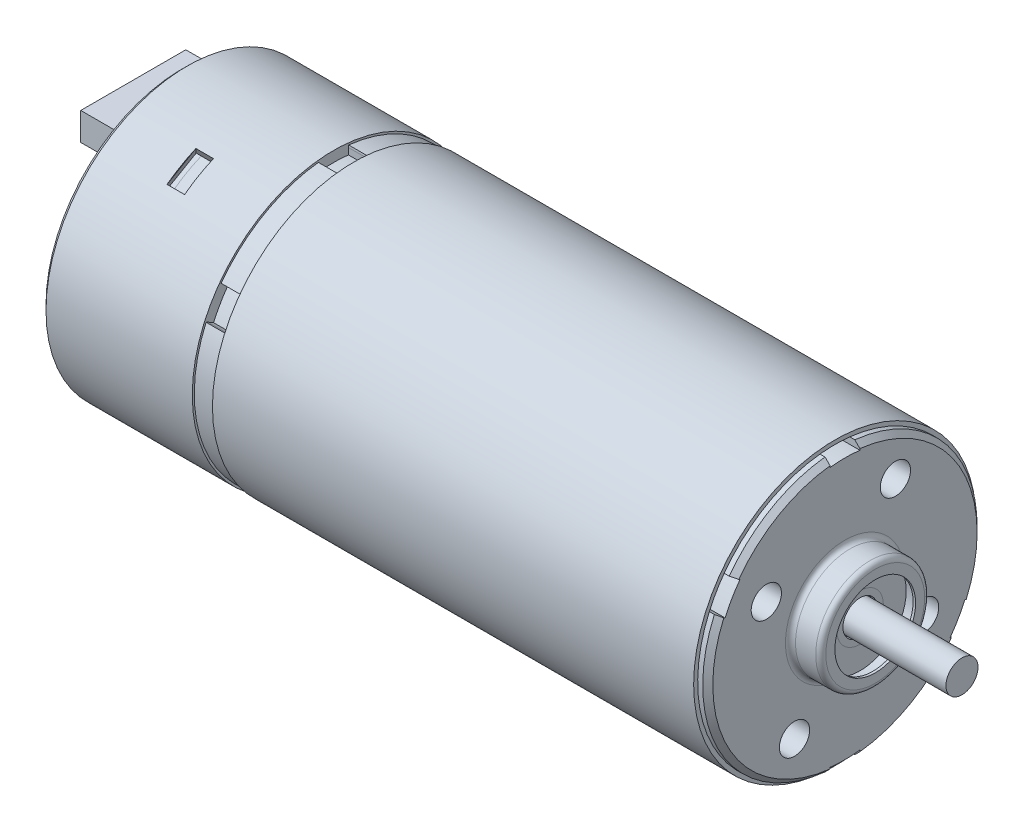
from build123d import *

# Parameters (mm, degrees)
SKETCH1_R               = 13.6
BOSS_EXTRUDE1_DEPTH     = 50.7
CUT_EXTRUDE1_DEPTH      = 55.225547485
SKETCH3_R               = 14
SKETCH3_R_2             = 13.6
BOSS_EXTRUDE2_DEPTH     = 47.7
SKETCH4_R               = 14
BOSS_EXTRUDE3_DEPTH     = 15
BOSS_EXTRUDE4_DEPTH     = 2
SKETCH6_R               = 1.5
CUT_EXTRUDE2_DEPTH      = 7
SKETCH7_R               = 5.4
BOSS_EXTRUDE5_DEPTH     = 3
SKETCH8_R               = 4
CUT_EXTRUDE3_DEPTH      = 1.5
SKETCH9_R               = 1.7
CUT_EXTRUDE4_DEPTH      = 0.5
SKETCH11_R              = 1.5875
BOSS_EXTRUDE6_DEPTH     = 10.6
SKETCH12_R              = 4.570841128
SKETCH12_R_2            = 4
CUT_EXTRUDE5_DEPTH      = 1.25
FILLET1_R               = 0.5
CHAMFER1_SIZE           = 0.5
CUT_EXTRUDE6_REACH      = 75.756
CUT_EXTRUDE6_END_RADIUS = 12.956768024
SKETCH13_W              = 1.739955734
SKETCH13_H              = 3.306373614
CUT_EXTRUDE7_DEPTH      = 0.5
CUT_EXTRUDE8_DEPTH      = 3.306373613
BOSS_EXTRUDE7_DEPTH     = 3.306373613
SKETCH17_W              = 10.414574722
SKETCH17_H              = 2.75
BOSS_EXTRUDE8_DEPTH     = 4.85
SKETCH18_W              = 9.614574722
SKETCH18_H              = 1.95
CUT_EXTRUDE10_DEPTH     = 4.85
SKETCH20_R              = 0.7
BOSS_EXTRUDE9_DEPTH     = 4.85


with BuildPart() as part:
    # Sketch1 → Boss-Extrude1 (new body)
    with BuildSketch(Plane(origin=(0, 0, 0), x_dir=(0, 0, -1), z_dir=(1, 0, 0))):
        Circle(SKETCH1_R)
    extrude(amount=-BOSS_EXTRUDE1_DEPTH)

    # Sketch2 → Cut-Extrude1 (cut, through all)
    with BuildSketch(Plane(origin=(0, 0, 0), x_dir=(0, 0, -1), z_dir=(1, 0, 0))):
        with BuildLine():
            Line((-1.476652596, 12.872347678), (-1.476652596, 14.372812182))
            Line((-1.476652596, 14.372812182), (1.476652596, 14.372812182))
            Line((1.476652596, 14.372812182), (1.476652596, 12.872347678))
            ThreePointArc((1.476652596, 12.872347678), (0, 12.956768024), (-1.476652596, 12.872347678))
        make_face()
        with BuildLine():
            Line((1.476652596, -12.872347678), (1.476652596, -14.372812182))
            Line((1.476652596, -14.372812182), (-1.476652596, -14.372812182))
            Line((-1.476652596, -14.372812182), (-1.476652596, -12.872347678))
            ThreePointArc((-1.476652596, -12.872347678), (0, -12.956768024), (1.476652596, -12.872347678))
        make_face()
        with BuildLine():
            Line((11.886106393, -5.157355179), (13.185546772, -5.907587431))
            Line((13.185546772, -5.907587431), (11.708894176, -8.465224751))
            Line((11.708894176, -8.465224751), (10.409453797, -7.714992499))
            ThreePointArc((10.409453797, -7.714992499), (11.220890259, -6.478384012), (11.886106393, -5.157355179))
        make_face()
        with BuildLine():
            Line((-11.886106393, 5.157355179), (-13.185546772, 5.907587431))
            Line((-13.185546772, 5.907587431), (-11.708894176, 8.465224751))
            Line((-11.708894176, 8.465224751), (-10.409453797, 7.714992499))
            ThreePointArc((-10.409453797, 7.714992499), (-11.220890259, 6.478384012), (-11.886106393, 5.157355179))
        make_face()
    extrude(amount=-CUT_EXTRUDE1_DEPTH, mode=Mode.SUBTRACT)



with BuildPart() as body_2:
    # Sketch3 → Boss-Extrude2 (new body)
    with BuildSketch(Plane(origin=(-1, 0, 0), x_dir=(0, 0, -1), z_dir=(1, 0, 0))):
        Circle(SKETCH3_R)
        Circle(SKETCH3_R_2, mode=Mode.SUBTRACT)
    extrude(amount=-BOSS_EXTRUDE2_DEPTH)


with BuildPart() as body_3:
    # Sketch4 → Boss-Extrude3 (new body)
    with BuildSketch(Plane.ZY.offset(50.7)):
        Circle(SKETCH4_R)
    extrude(amount=BOSS_EXTRUDE3_DEPTH)


with BuildPart() as part_1:
    add(part.part)

    add(body_2.part)  # Boss-Extrude4 merges body 2

    add(body_3.part)  # Boss-Extrude4 merges body 3
    # Sketch5 → Boss-Extrude4 (add)
    with BuildSketch(Plane(origin=(-50.7, 0, 0), x_dir=(0, 0, -1), z_dir=(1, 0, 0))):
        with BuildLine():
            Line((1.476652596, 13.519596781), (1.498368075, 13.71841438))
            ThreePointArc((1.498368075, 13.71841438), (11.951150572, 6.9), (12.629679391, -5.561582373))
            Line((12.629679391, -5.561582373), (12.446640559, -5.48097973))
            ThreePointArc((12.446640559, -5.48097973), (11.777945491, 6.8), (1.476652596, 13.519596781))
        make_face()
        with BuildLine():
            Line((-1.476652596, 13.519596781), (-1.498368075, 13.71841438))
            ThreePointArc((-1.498368075, 13.71841438), (-6.9, 11.951150572), (-11.131311316, 8.156832007))
            Line((-11.131311316, 8.156832007), (-10.969987963, 8.038617051))
            ThreePointArc((-10.969987963, 8.038617051), (-6.8, 11.777945491), (-1.476652596, 13.519596781))
        make_face()
        with BuildLine():
            Line((10.969987963, -8.038617051), (11.131311316, -8.156832007))
            ThreePointArc((11.131311316, -8.156832007), (6.9, -11.951150572), (1.498368075, -13.71841438))
            Line((1.498368075, -13.71841438), (1.476652596, -13.519596781))
            ThreePointArc((1.476652596, -13.519596781), (6.8, -11.777945491), (10.969987963, -8.038617051))
        make_face()
        with BuildLine():
            Line((-1.476652596, -13.519596781), (-1.498368075, -13.71841438))
            ThreePointArc((-1.498368075, -13.71841438), (-11.951150572, -6.9), (-12.629679391, 5.561582373))
            Line((-12.629679391, 5.561582373), (-12.446640559, 5.48097973))
            ThreePointArc((-12.446640559, 5.48097973), (-11.777945491, -6.8), (-1.476652596, -13.519596781))
        make_face()
    extrude(amount=BOSS_EXTRUDE4_DEPTH)

    # Sketch6 → Cut-Extrude2 (cut)
    with BuildSketch(Plane(origin=(0, 0, 0), x_dir=(0, 0, -1), z_dir=(1, 0, 0))):
        with Locations((-5, -8.660254038)):
            Circle(SKETCH6_R)
        with Locations((5, 8.660254038)):
            Circle(SKETCH6_R)
        with Locations((-7.794228634, 4.5)):
            Circle(SKETCH6_R)
        with Locations((7.794228634, -4.5)):
            Circle(SKETCH6_R)
    extrude(amount=-CUT_EXTRUDE2_DEPTH, mode=Mode.SUBTRACT)

    # Sketch7 → Boss-Extrude5 (add)
    with BuildSketch(Plane(origin=(0, 0, 0), x_dir=(0, 0, -1), z_dir=(1, 0, 0))):
        Circle(SKETCH7_R)
    extrude(amount=BOSS_EXTRUDE5_DEPTH)

    # Sketch8 → Cut-Extrude3 (cut)
    with BuildSketch(Plane(origin=(3, 0, 0), x_dir=(0, 0, -1), z_dir=(1, 0, 0))):
        Circle(SKETCH8_R)
    extrude(amount=-CUT_EXTRUDE3_DEPTH, mode=Mode.SUBTRACT)

    # Sketch9 → Cut-Extrude4 (cut)
    with BuildSketch(Plane(origin=(1.5, 0, 0), x_dir=(0, 0, -1), z_dir=(1, 0, 0))):
        Circle(SKETCH9_R)
    extrude(amount=-CUT_EXTRUDE4_DEPTH, mode=Mode.SUBTRACT)

    # Sketch12 → Cut-Extrude5 (cut)
    with BuildSketch(Plane(origin=(1.5, 0, 0), x_dir=(0, 0, -1), z_dir=(1, 0, 0))):
        Circle(SKETCH12_R)
        Circle(SKETCH12_R_2, mode=Mode.SUBTRACT)
    extrude(amount=CUT_EXTRUDE5_DEPTH, mode=Mode.SUBTRACT)

    # Fillet1
    fillet1_edges = [part_1.edges().sort_by_distance(p)[0] for p in [
        (0, 0, 5.4),
        (3, 0, 5.4),
    ]]
    fillet(fillet1_edges, radius=FILLET1_R)

    # Chamfer1
    chamfer1_edges = [part_1.edges().sort_by_distance(p)[0] for p in [
        (-65.7, 0, -14),
        (0, 11.777945491, 6.8),
        (0, -6.8, 11.777945491),
        (0, -11.777945491, -6.8),
        (0, 6.8, -11.777945491),
    ]]
    chamfer(chamfer1_edges, length=CHAMFER1_SIZE)

    # Cut-Extrude6: up to this cylinder (the profile starts outside it)
    cut_extrude6_end = Plane(origin=(-57.95, 0, 0), z_dir=(1, 0, 0)) * Cylinder(CUT_EXTRUDE6_END_RADIUS, 178.425536047, mode=Mode.PRIVATE)
    # Sketch13 → Cut-Extrude6 (cut, up to the surface)
    with BuildSketch(Plane(origin=(0, 12.124355653, 7), x_dir=(1, 0, 0), z_dir=(0, 0.866025403784438, 0.500000000000001)), mode=Mode.PRIVATE) as cut_extrude6_sk1:
        with Locations((-57.95, 0)):
            Rectangle(SKETCH13_W, SKETCH13_H)
    cut_extrude6_tool1 = extrude(cut_extrude6_sk1.sketch, amount=-CUT_EXTRUDE6_REACH, mode=Mode.PRIVATE) - cut_extrude6_end
    cut_extrude6 = cut_extrude6_tool1.solids().sort_by_distance((-57.95, 12.124356, 7))[0]
    add(cut_extrude6, mode=Mode.SUBTRACT)

    # Sketch14 → Cut-Extrude7 (cut)
    with BuildSketch(Plane(origin=(-58.819977867, 0, 0), x_dir=(0, 0, -1), z_dir=(1, 0, 0))):
        with BuildLine():
            Line((-5.256527567, 12.41094643), (-8.11993111, 10.757759624))
            Line((-8.11993111, 10.757759624), (-7.857135823, 10.302584835))
            ThreePointArc((-7.857135823, 10.302584835), (-6.478384012, 11.220890259), (-4.99373228, 11.955771641))
            Line((-4.99373228, 11.955771641), (-5.256527567, 12.41094643))
        make_face()
    cut_extrude7 = extrude(amount=-CUT_EXTRUDE7_DEPTH, mode=Mode.SUBTRACT)

    # Sketch15 → Cut-Extrude8 (cut)
    with BuildSketch(Plane(origin=(0, 0.826593403, -1.431701772), x_dir=(1, 0, 0), z_dir=(0, -0.5000000000000012, 0.866025403784438))):
        Polygon((-58.819977867, 13.902049251), (-59.319977867, 12.850868103), (-58.819977867, 12.850868103), align=None)
    cut_extrude8 = extrude(amount=CUT_EXTRUDE8_DEPTH, mode=Mode.SUBTRACT)

    # Sketch16 → Boss-Extrude7 (add)
    with BuildSketch(Plane(origin=(0, 0.826593403, -1.431701772), x_dir=(1, 0, 0), z_dir=(0, -0.5000000000000012, 0.866025403784438))):
        Polygon((-59.069977867, 13.376458677), (-59.319977867, 12.850868103), (-59.319977867, 13.376458677), align=None)
    boss_extrude7 = extrude(amount=BOSS_EXTRUDE7_DEPTH)

    # Mirror1: Cut-Extrude6, Cut-Extrude7, Cut-Extrude8, Boss-Extrude7 across plane
    add(cut_extrude6.mirror(Plane(origin=(0, 0, 0), x_dir=(0, -0.500000000000001, 0.866025403784438), z_dir=(0, 0.866025403784438, 0.500000000000001))), mode=Mode.SUBTRACT)
    add(cut_extrude7.mirror(Plane(origin=(0, 0, 0), x_dir=(0, -0.500000000000001, 0.866025403784438), z_dir=(0, 0.866025403784438, 0.500000000000001))), mode=Mode.SUBTRACT)
    add(cut_extrude8.mirror(Plane(origin=(0, 0, 0), x_dir=(0, -0.500000000000001, 0.866025403784438), z_dir=(0, 0.866025403784438, 0.500000000000001))), mode=Mode.SUBTRACT)
    add(boss_extrude7.mirror(Plane(origin=(0, 0, 0), x_dir=(0, -0.500000000000001, 0.866025403784438), z_dir=(0, 0.866025403784438, 0.500000000000001))))


with BuildPart() as body_2_2:
    # Sketch11 → Boss-Extrude6 (new body)
    with BuildSketch(Plane(origin=(1, 0, 0), x_dir=(0, 0, -1), z_dir=(1, 0, 0))):
        Circle(SKETCH11_R)
    extrude(amount=BOSS_EXTRUDE6_DEPTH)


with BuildPart() as body_3_2:
    # Sketch17 → Boss-Extrude8 (new body)
    with BuildSketch(Plane.ZY.offset(65.7)):
        with Locations((0, 8.736671017)):
            Rectangle(SKETCH17_W, SKETCH17_H)
    extrude(amount=BOSS_EXTRUDE8_DEPTH)

    # Sketch18 → Cut-Extrude10 (cut)
    with BuildSketch(Plane.ZY.offset(70.55)):
        with Locations((0, 8.736671017)):
            Rectangle(SKETCH18_W, SKETCH18_H)
    extrude(amount=-CUT_EXTRUDE10_DEPTH, mode=Mode.SUBTRACT)


    add(part_1.part)  # Boss-Extrude9 merges part
    # Sketch20 → Boss-Extrude9 (add)
    with BuildSketch(Plane.ZY.offset(65.7)):
        with Locations(Location((0, 8.736671017, 0), (0, 0, 180))):
            Circle(SKETCH20_R)
        with Locations(Location((1.8, 8.736671017, 0), (0, 0, 180))):
            Circle(SKETCH20_R)
        with Locations(Location((3.6, 8.736671017, 0), (0, 0, 180))):
            Circle(SKETCH20_R)
        with Locations(Location((-1.8, 8.736671017, 0), (0, 0, 180))):
            Circle(SKETCH20_R)
        with Locations(Location((-3.6, 8.736671017, 0), (0, 0, 180))):
            Circle(SKETCH20_R)
    extrude(amount=BOSS_EXTRUDE9_DEPTH)


solid = Compound([body_2_2.part, body_3_2.part])
